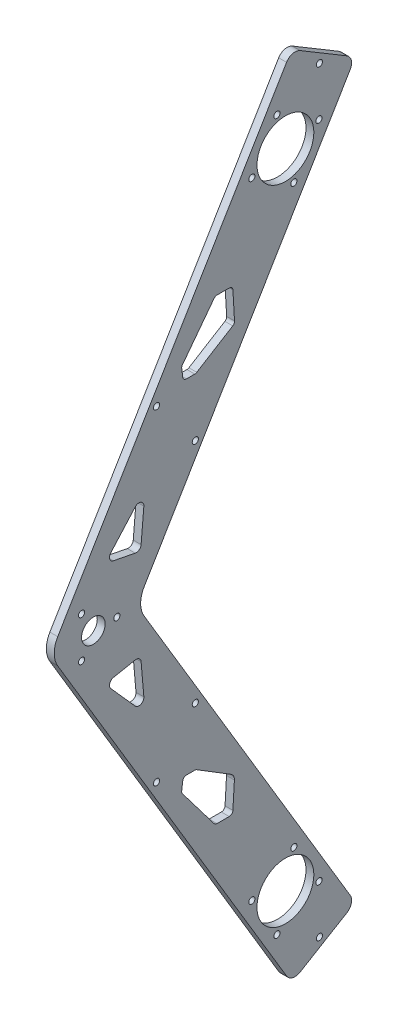
from build123d import *

# Parameters (mm, degrees)
EXTRUDE_BASE_DEPTH         = 3.18
SKETCH4_R                  = 11.5
CUT_MOTOR_HOLES_DEPTH      = 3.18
SKETCH5_R                  = 1.25
MOTOR_SUPPORT_HOLES_DEPTH  = 3.18
SKETCH6_R                  = 1.25
SKETCH6_R_2                = 4.765
SUPPORT_HOLES_DEPTH        = 3.18
CUT_LIGHTENING_HOLES_DEPTH = 3.18


with BuildPart() as part:
    # bogie base → extrude-base (new body)
    with BuildSketch(Plane.YZ):
        with BuildLine():
            Line((-31.39506552, -5.945574909), (-20.11035906, -24.830897255))
            ThreePointArc((-20.11035906, -24.830897255), (-17.653836276, -26.657938255), (-14.624899277, -26.212827416))
            Line((-14.624899277, -26.212827416), (124.870587973, 57.141091427))
            ThreePointArc((124.870587973, 57.141091427), (130, 58.556853997), (135.129412027, 57.141091427))
            Line((135.129412027, 57.141091427), (274.624899277, -26.212827416))
            ThreePointArc((274.624899277, -26.212827416), (277.653836276, -26.657938255), (280.11035906, -24.830897255))
            Line((280.11035906, -24.830897255), (291.39506552, -5.945574909))
            ThreePointArc((291.39506552, -5.945574909), (291.840176358, -2.91663791), (290.013135359, -0.460115126))
            Line((290.013135359, -0.460115126), (135.129412027, 92.088866631))
            ThreePointArc((135.129412027, 92.088866631), (130, 93.504629201), (124.870587973, 92.088866631))
            Line((124.870587973, 92.088866631), (-30.013135359, -0.460115126))
            ThreePointArc((-30.013135359, -0.460115126), (-31.840176358, -2.91663791), (-31.39506552, -5.945574909))
        make_face()
    extrude(amount=EXTRUDE_BASE_DEPTH)

    # Sketch4 → Cut-motor holes (cut)
    with BuildSketch(Plane.YZ):
        with Locations((260, 0)):
            Circle(SKETCH4_R)
        Circle(SKETCH4_R)
    extrude(amount=CUT_MOTOR_HOLES_DEPTH, mode=Mode.SUBTRACT)

    # Sketch5 → motor support holes (cut)
    with BuildSketch(Plane.YZ):
        with Locations((3.419410151, 13.575994778)):
            Circle(SKETCH5_R)
        with Locations((-3.41941001, -13.575994814)):
            Circle(SKETCH5_R)
        with Locations((13.577380102, -3.419759)):
            Circle(SKETCH5_R)
        with Locations((-13.57737996, 3.419758964)):
            Circle(SKETCH5_R)
        with Locations((273.57737996, 3.419758964)):
            Circle(SKETCH5_R)
        with Locations((246.422619898, -3.419759)):
            Circle(SKETCH5_R)
        with Locations((263.41941001, -13.575994814)):
            Circle(SKETCH5_R)
        with Locations((256.580589849, 13.575994778)):
            Circle(SKETCH5_R)
    extrude(amount=MOTOR_SUPPORT_HOLES_DEPTH, mode=Mode.SUBTRACT)

    # Sketch6 → support holes (cut)
    with BuildSketch(Plane.YZ):
        with Locations((64.164835578, 52.110380567)):
            Circle(SKETCH6_R)
        with Locations((84.016579298, 36.433714107)):
            Circle(SKETCH6_R)
        with Locations((130, 77.68)):
            Circle(SKETCH6_R_2)
        with Locations((130, 68.17)):
            Circle(SKETCH6_R)
        with Locations((121.77231361, 82.449200841)):
            Circle(SKETCH6_R)
        with Locations((138.248750332, 82.43704307)):
            Circle(SKETCH6_R)
        with Locations((175.983420702, 36.433714107)):
            Circle(SKETCH6_R)
        with Locations((195.835164422, 52.110380567)):
            Circle(SKETCH6_R)
        with Locations((-23.022924787, -13.757083057)):
            Circle(SKETCH6_R)
        with Locations((283.022924787, -13.757083057)):
            Circle(SKETCH6_R)
    extrude(amount=SUPPORT_HOLES_DEPTH, mode=Mode.SUBTRACT)

    # Sketch7 → Cut-lightening holes (cut)
    with BuildSketch(Plane.YZ):
        with BuildLine():
            Line((54.884000108, 41.646401467), (38.03439682, 28.860792879))
            ThreePointArc((38.03439682, 28.860792879), (37.597600164, 28.332915929), (37.441118366, 27.665863577))
            Line((37.441118366, 27.665863577), (37.441118366, 22.734591544))
            ThreePointArc((37.441118366, 22.734591544), (37.849837551, 21.705462697), (38.853259944, 21.237166789))
            Line((38.853259944, 21.237166789), (49.165938422, 20.63209087))
            ThreePointArc((49.165938422, 20.63209087), (50.727348318, 20.966140733), (51.896208282, 22.053962665))
            Line((51.896208282, 22.053962665), (60.398420976, 35.861757183))
            ThreePointArc((60.398420976, 35.861757183), (60.564389902, 36.239537563), (60.621144468, 36.64824604))
            Line((60.621144468, 36.64824604), (60.621144468, 40.036157787))
            ThreePointArc((60.621144468, 40.036157787), (60.245516663, 41.02902594), (59.306761578, 41.524628912))
            Line((59.306761578, 41.524628912), (55.976338764, 41.939943289))
            ThreePointArc((55.976338764, 41.939943289), (55.401440776, 41.900078528), (54.884000108, 41.646401467))
        make_face()
        with BuildLine():
            Line((200.693238422, 41.524628912), (204.023661236, 41.939943289))
            ThreePointArc((204.023661236, 41.939943289), (204.598559224, 41.900078528), (205.115999892, 41.646401467))
            Line((205.115999892, 41.646401467), (221.96560318, 28.860792879))
            ThreePointArc((221.96560318, 28.860792879), (222.402399836, 28.332915929), (222.558881634, 27.665863577))
            Line((222.558881634, 27.665863577), (222.558881634, 22.734591544))
            ThreePointArc((222.558881634, 22.734591544), (222.150162449, 21.705462697), (221.146740056, 21.237166789))
            Line((221.146740056, 21.237166789), (209.939024731, 20.579576362))
            ThreePointArc((209.939024731, 20.579576362), (209.158319783, 20.746601293), (208.573889801, 21.290512259))
            Line((208.573889801, 21.290512259), (199.601579024, 35.861757183))
            ThreePointArc((199.601579024, 35.861757183), (199.435610098, 36.239537563), (199.378855532, 36.64824604))
            Line((199.378855532, 36.64824604), (199.378855532, 40.036157787))
            ThreePointArc((199.378855532, 40.036157787), (199.754483337, 41.02902594), (200.693238422, 41.524628912))
        make_face()
        with BuildLine():
            Line((106.261574004, 70.658830934), (95.113053624, 60.737670596))
            ThreePointArc((95.113053624, 60.737670596), (94.605778471, 58.452426038), (96.614841284, 57.251036263))
            Line((96.614841284, 57.251036263), (109.502121723, 58.364828314))
            ThreePointArc((109.502121723, 58.364828314), (110.928310049, 59.155267125), (111.292040735, 60.744765992))
            Line((111.292040735, 60.744765992), (109.553280676, 69.552134278))
            ThreePointArc((109.553280676, 69.552134278), (108.22850953, 71.060494424), (106.261574004, 70.658830934))
        make_face()
        with BuildLine():
            Line((148.707959265, 60.744765992), (150.446719324, 69.552134278))
            ThreePointArc((150.446719324, 69.552134278), (151.77149047, 71.060494424), (153.738425996, 70.658830934))
            Line((153.738425996, 70.658830934), (164.886946376, 60.737670596))
            ThreePointArc((164.886946376, 60.737670596), (165.394221529, 58.452426038), (163.385158716, 57.251036263))
            Line((163.385158716, 57.251036263), (150.497878277, 58.364828314))
            ThreePointArc((150.497878277, 58.364828314), (149.071689951, 59.155267125), (148.707959265, 60.744765992))
        make_face()
    extrude(amount=CUT_LIGHTENING_HOLES_DEPTH, mode=Mode.SUBTRACT)


solid = part.part
